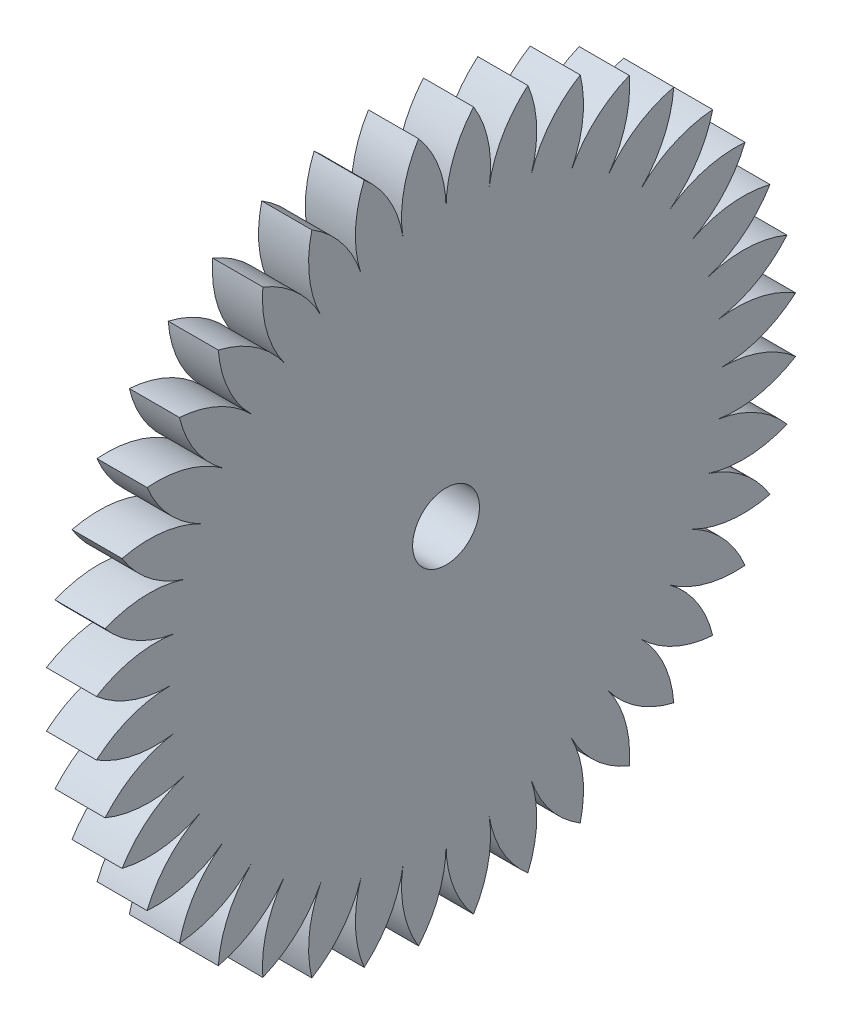
from build123d import *

# Parameters (mm, degrees)
BOSS_EXTRUDE1_DEPTH = 3
CIRPATTERN1_COUNT   = 40
SKETCH2_R           = 2
CUT_EXTRUDE2_DEPTH  = 4


with BuildPart() as part:
    # Sketch1 → Boss-Extrude1 (new body)
    with BuildSketch(Plane(origin=(0, 0, 0), x_dir=(0, 0, -1), z_dir=(1, 0, 0))):
        with BuildLine():
            Line((0, 16.5), (0, 0))
            Line((0, 0), (2.581168673, 16.29685762))
            ThreePointArc((2.581168673, 16.29685762), (2.531264023, 18.699958072), (1.64764101, 20.935264008))
            ThreePointArc((1.64764101, 20.935264008), (0.425217975, 18.865707491), (0, 16.5))
        make_face()
    boss_extrude1 = extrude(amount=BOSS_EXTRUDE1_DEPTH)

    # CirPattern1: Boss-Extrude1 ×40 about axis
    cirpattern1_axis = Axis((0, 0, 0), (1, 0, 0))
    for i in range(1, CIRPATTERN1_COUNT):
        add(boss_extrude1.rotate(cirpattern1_axis, i * 360 / CIRPATTERN1_COUNT))

    # Sketch2 → Cut-Extrude2 (cut, through all)
    with BuildSketch(Plane(origin=(0, 0, 0), x_dir=(0, 0, -1), z_dir=(1, 0, 0))):
        Circle(SKETCH2_R)
    extrude(amount=CUT_EXTRUDE2_DEPTH, mode=Mode.SUBTRACT)


solid = part.part
